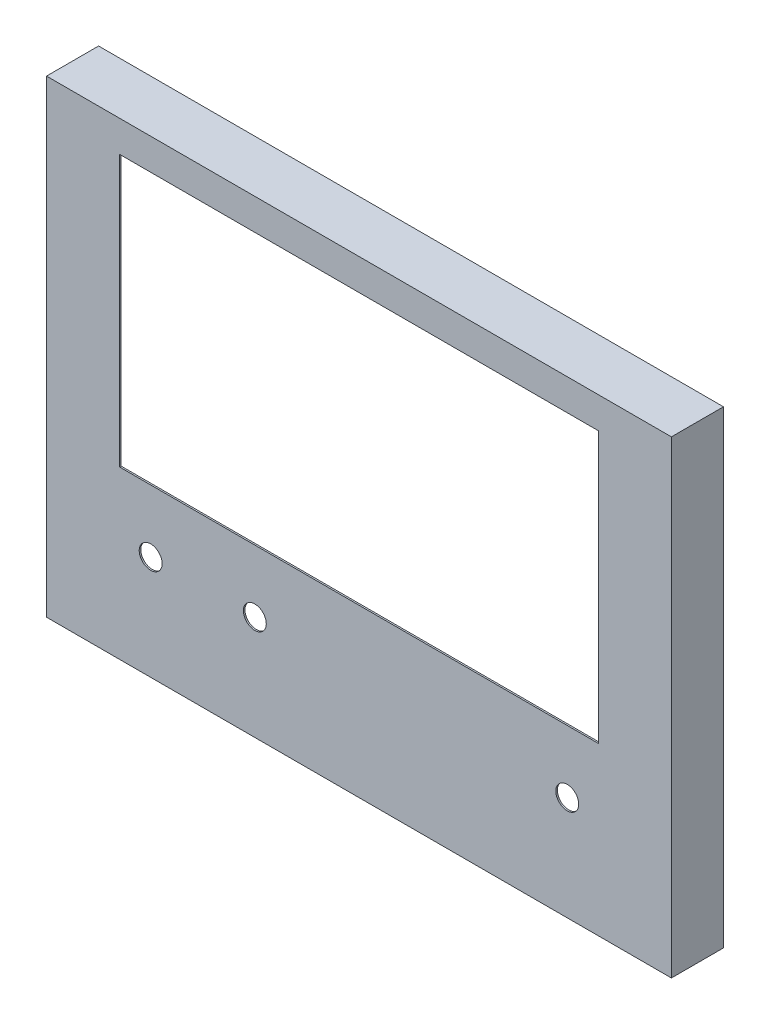
from build123d import *

# Parameters (mm, degrees)
SKETCH1_W           = 600
SKETCH1_H           = 450
BOSS_EXTRUDE1_DEPTH = 50
SHELL1_T            = -1.5
CUT_EXTRUDE1_REACH  = 52
SKETCH3_W           = 460
SKETCH3_H           = 260
CUT_EXTRUDE2_REACH  = 52
SKETCH4_R           = 11


with BuildPart() as part:
    # Sketch1 → Boss-Extrude1 (new body)
    with BuildSketch(Plane.XY):
        Rectangle(SKETCH1_W, SKETCH1_H)
    extrude(amount=BOSS_EXTRUDE1_DEPTH)

    # Shell1
    shell1_openings = [part.faces().sort_by_distance(p)[0] for p in [
        (0, 0, 0),
    ]]
    offset(amount=SHELL1_T, openings=shell1_openings, kind=Kind.INTERSECTION)

    # Sketch3 → Cut-Extrude1 (cut, up to next)
    with BuildSketch(Plane.XY.offset(50), mode=Mode.PRIVATE) as cut_extrude1_sk1:
        with Locations((0, 65)):
            Rectangle(SKETCH3_W, SKETCH3_H)
    cut_extrude1_tool1 = extrude(cut_extrude1_sk1.sketch, amount=-CUT_EXTRUDE1_REACH, mode=Mode.PRIVATE) & part.part
    add(cut_extrude1_tool1.solids().sort_by_distance((0, 65, 50))[0], mode=Mode.SUBTRACT)

    # Sketch4 → Cut-Extrude2 (cut, up to next)
    with BuildSketch(Plane.XY.offset(50), mode=Mode.PRIVATE) as cut_extrude2_sk1:
        with Locations((-200, -125)):
            Circle(SKETCH4_R)
    cut_extrude2_tool1 = extrude(cut_extrude2_sk1.sketch, amount=-CUT_EXTRUDE2_REACH, mode=Mode.PRIVATE) & part.part
    add(cut_extrude2_tool1.solids().sort_by_distance((-200, -125, 50))[0], mode=Mode.SUBTRACT)
    # Sketch4 → Cut-Extrude2 (cut, up to next)
    with BuildSketch(Plane.XY.offset(50), mode=Mode.PRIVATE) as cut_extrude2_sk2:
        with Locations((200, -125)):
            Circle(SKETCH4_R)
    cut_extrude2_tool2 = extrude(cut_extrude2_sk2.sketch, amount=-CUT_EXTRUDE2_REACH, mode=Mode.PRIVATE) & part.part
    add(cut_extrude2_tool2.solids().sort_by_distance((200, -125, 50))[0], mode=Mode.SUBTRACT)
    # Sketch4 → Cut-Extrude2 (cut, up to next)
    with BuildSketch(Plane.XY.offset(50), mode=Mode.PRIVATE) as cut_extrude2_sk3:
        with Locations((-100, -125)):
            Circle(SKETCH4_R)
    cut_extrude2_tool3 = extrude(cut_extrude2_sk3.sketch, amount=-CUT_EXTRUDE2_REACH, mode=Mode.PRIVATE) & part.part
    add(cut_extrude2_tool3.solids().sort_by_distance((-100, -125, 50))[0], mode=Mode.SUBTRACT)


solid = part.part
